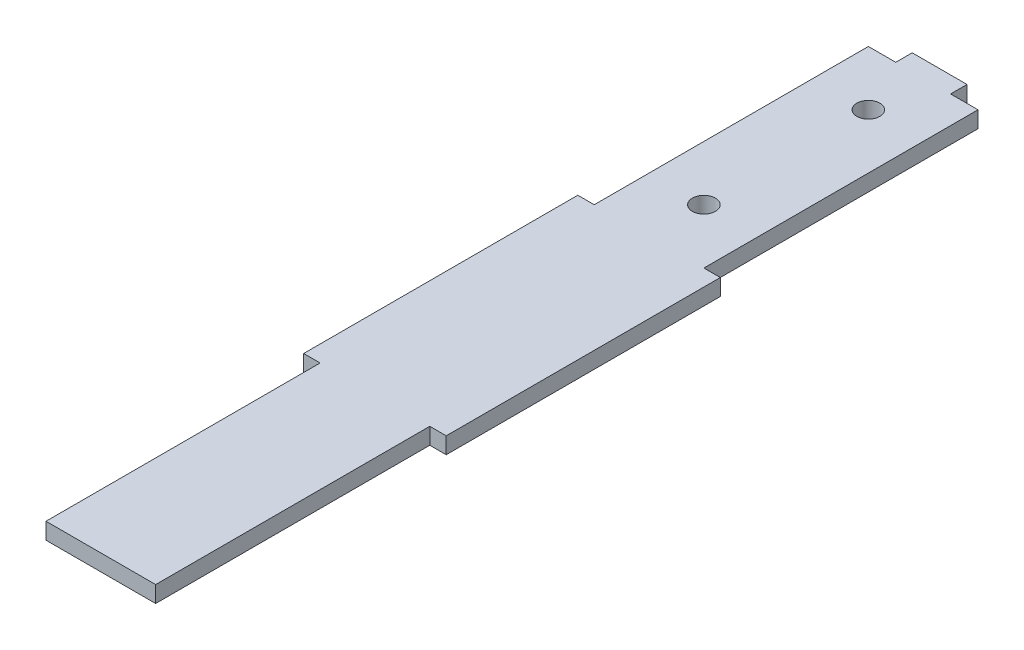
from build123d import *

# Parameters (mm, degrees)
BOSS_EXTRUDE1_DEPTH = 3
SKETCH2_R           = 2.1
CUT_EXTRUDE1_DEPTH  = 4


with BuildPart() as part:
    # Sketch1 → Boss-Extrude1 (new body)
    with BuildSketch(Plane(origin=(0, 0, 0), x_dir=(1, 0, 0), z_dir=(0, 1, 0))):
        Polygon((15, 0), (20, 0), (20, -50), (23, -50), (23, -100), (20, -100), (20, -150), (0, -150), (0, -100), (-3, -100), (-3, -50), (0, -50), (0, 0), (5, 0), (5, 3), (15, 3), align=None)
    extrude(amount=BOSS_EXTRUDE1_DEPTH)

    # Sketch2 → Cut-Extrude1 (cut, through all)
    with BuildSketch(Plane(origin=(0, 3, 0), x_dir=(1, 0, 0), z_dir=(0, 1, 0))):
        with Locations((10, -10)):
            Circle(SKETCH2_R)
        with Locations((10, -40)):
            Circle(SKETCH2_R)
    extrude(amount=-CUT_EXTRUDE1_DEPTH, mode=Mode.SUBTRACT)


solid = part.part
